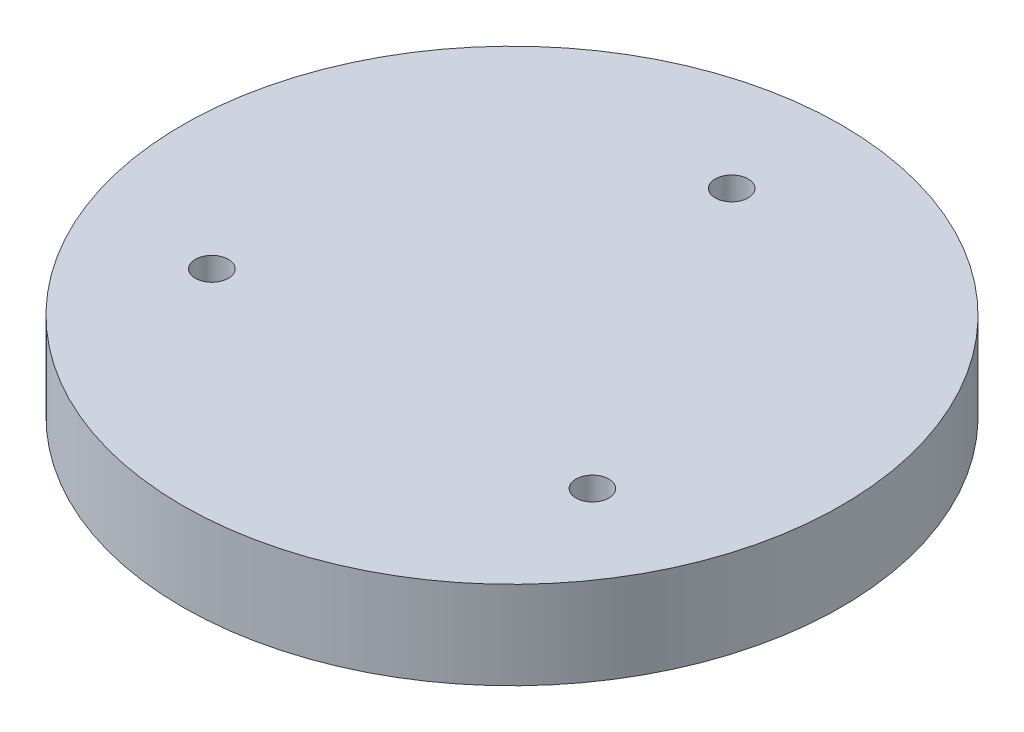
from build123d import *

# Parameters (mm, degrees)
SKETCH_1_R          = 30
EXTRUDE_1_DEPTH     = 8
SKETCH_2_R          = 1.5
CUT_EXTRUDE_1_DEPTH = 8


with BuildPart() as part:
    # 草图1 → 凸台-拉伸1 (new body)
    with BuildSketch(Plane(origin=(0, 0, 0), x_dir=(1, 0, 0), z_dir=(0, 1, 0))):
        Circle(SKETCH_1_R)
    extrude(amount=EXTRUDE_1_DEPTH)

    # 草图2 → 切除-拉伸1 (cut)
    with BuildSketch(Plane(origin=(0, 8, 0), x_dir=(1, 0, 0), z_dir=(0, 1, 0))):
        with Locations((0, 20)):
            Circle(SKETCH_2_R)
        with Locations((17.320508076, -10)):
            Circle(SKETCH_2_R)
        with Locations((-17.320508076, -10)):
            Circle(SKETCH_2_R)
    extrude(amount=-CUT_EXTRUDE_1_DEPTH, mode=Mode.SUBTRACT)


solid = part.part
